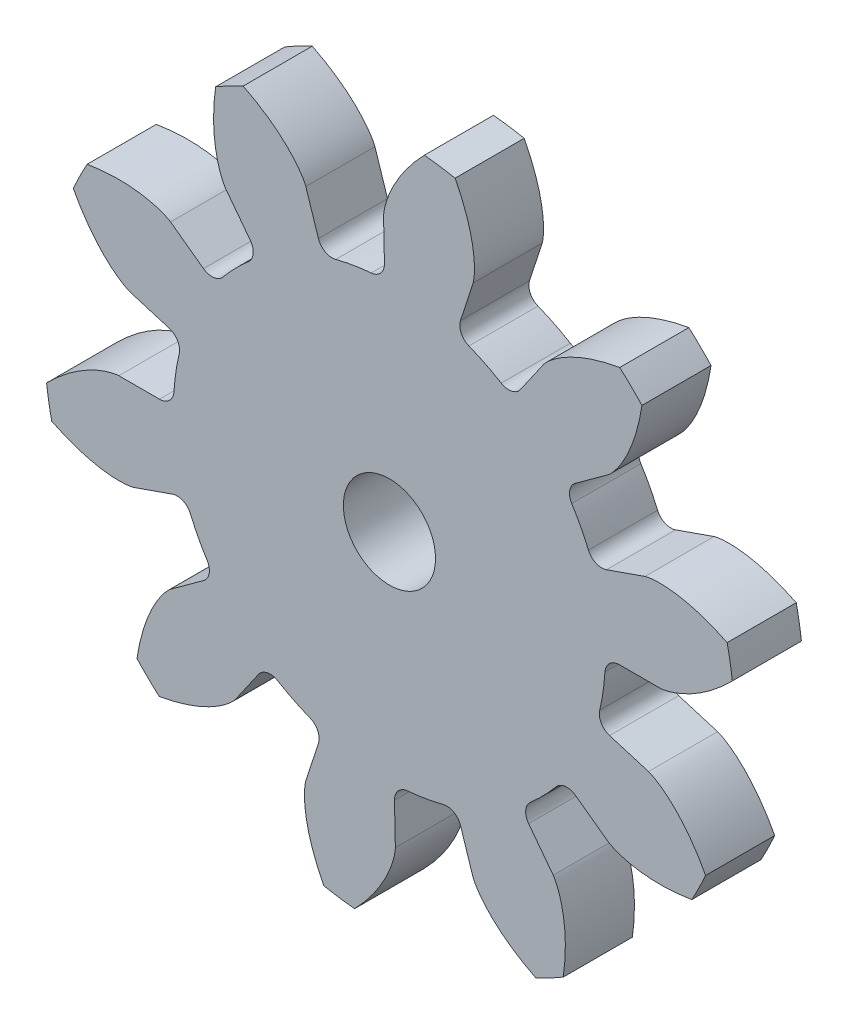
from build123d import *

# Parameters (mm, degrees)
BOSS_EXTRUDE3_DEPTH      = 3
FILLET1_R                = 0.625
CIRPATTERN8_COUNT        = 10
CIRPATTERN8_COPY_1_DEPTH = 3
CIRPATTERN8_COPY_2_DEPTH = 3
CIRPATTERN8_COPY_3_DEPTH = 3
CIRPATTERN8_COPY_4_DEPTH = 3
CIRPATTERN8_COPY_5_DEPTH = 3
CIRPATTERN8_COPY_6_DEPTH = 3
CIRPATTERN8_COPY_7_DEPTH = 3
CIRPATTERN8_COPY_8_DEPTH = 3
CIRPATTERN8_COPY_9_DEPTH = 3
FILLET1_OF_CIRPATTERN8_R = 0.625
SKETCH3_R                = 2
CUT_EXTRUDE2_DEPTH       = 4.0000001


with BuildPart() as part:
    # Sketch1 → Boss-Extrude3 (new body)
    with BuildSketch(Plane.XY):
        with BuildLine():
            Line((9.375, 0), (11.74615776, 0))
            add(Edge.make_bspline(
                [(11.74615776, 0), (11.754841732, 0.000183768), (11.779179169, 0.001267888), (11.825088632, 0.005562117), (11.899691958, 0.015746104), (11.994171849, 0.033372696), (12.115394291, 0.0614606), (12.256834487, 0.101322639), (12.410572757, 0.152161687), (12.575722813, 0.214972968), (12.738406771, 0.284201046), (12.898564829, 0.359289485), (13.056063732, 0.439482048), (13.244229139, 0.542891509), (13.466087479, 0.675556037), (13.719390719, 0.842943905), (13.999170912, 1.047118123), (14.275580492, 1.270025494), (14.531397244, 1.493742481), (14.716666587, 1.670363519), (14.8331519, 1.786067897), (14.886668048, 1.84041148)],
                knots=[0, 0, 0, 0, 0, 0.005376748, 0.015083688, 0.02853182, 0.046610139, 0.064854849, 0.092110525, 0.119476175, 0.146842495, 0.174208853, 0.201574955, 0.228941013, 0.256307345, 0.307035032, 0.361767351, 0.41649966, 0.471231936, 0.525964281, 0.573449371, 0.573449371, 0.573449371, 0.573449371, 0.573449371], degree=4))
            ThreePointArc((14.886668048, 1.84041148), (14.841516096, 2.174718367), (14.788857648, 2.507925333))
            Line((14.788857648, 2.507925333), (9.24303603, 1.567453333))
            ThreePointArc((9.24303603, 1.567453333), (9.341950754, 0.786499275), (9.375, 0))
        make_face()
        with BuildLine():
            ThreePointArc((-9.24303603, -1.567453333), (0.786499275, -9.341950754), (9.375, 0))
            ThreePointArc((9.375, 0), (9.341950754, 0.786499275), (9.24303603, 1.567453333))
            Line((9.24303603, 1.567453333), (-9.24303603, -1.567453333))
        make_face()
        with BuildLine():
            Line((-9.24303603, -1.567453333), (9.24303603, 1.567453333))
            ThreePointArc((9.24303603, 1.567453333), (-1.567453333, 9.24303603), (-9.24303603, -1.567453333))
        make_face()
    boss_extrude3 = extrude(amount=BOSS_EXTRUDE3_DEPTH)

    # Mirror2: Boss-Extrude3 across plane
    add(boss_extrude3.mirror(Plane(origin=(0, 0, 3), x_dir=(0, 0, 1), z_dir=(0.167195022, -0.985923843, 0))))

    # Fillet1
    fillet1_edges = [part.edges().sort_by_distance(p)[0] for p in [
        (9.375, 0, 1.5),
        (8.850859211, 3.090779228, 1.5),
    ]]
    fillet(fillet1_edges, radius=FILLET1_R)

    # CirPattern8: Boss-Extrude3 ×10 about axis
    cirpattern8_axis = Axis((0, 0, 3), (0, 0, -1))
    for i in range(1, CIRPATTERN8_COUNT):
        add(boss_extrude3.rotate(cirpattern8_axis, i * 360 / CIRPATTERN8_COUNT))

    # CirPattern8 copy 1 sketch → CirPattern8 copy 1 (add)
    with BuildSketch(Plane(origin=(0, 0, 0), x_dir=(0.957569063, -0.288203903, 0), z_dir=(0, 0, 1))):
        with BuildLine():
            Line((9.375, 0), (11.74615776, 0))
            add(Edge.make_bspline(
                [(11.74615776, 0), (11.754841732, -0.000183768), (11.779179169, -0.001267888), (11.825088632, -0.005562117), (11.899691958, -0.015746104), (11.994171849, -0.033372696), (12.115394291, -0.0614606), (12.256834487, -0.101322639), (12.410572757, -0.152161687), (12.575722813, -0.214972968), (12.738406771, -0.284201046), (12.898564829, -0.359289485), (13.056063732, -0.439482048), (13.244229139, -0.542891509), (13.466087479, -0.675556037), (13.719390719, -0.842943905), (13.999170912, -1.047118123), (14.275580492, -1.270025494), (14.531397244, -1.493742481), (14.716666587, -1.670363519), (14.8331519, -1.786067897), (14.886668048, -1.84041148)],
                knots=[0, 0, 0, 0, 0, 0.005376748, 0.015083688, 0.02853182, 0.046610139, 0.064854849, 0.092110525, 0.119476175, 0.146842495, 0.174208853, 0.201574955, 0.228941013, 0.256307345, 0.307035032, 0.361767351, 0.41649966, 0.471231936, 0.525964281, 0.573449371, 0.573449371, 0.573449371, 0.573449371, 0.573449371], degree=4))
            ThreePointArc((14.886668048, -1.84041148), (14.841516096, -2.174718367), (14.788857648, -2.507925333))
            Line((14.788857648, -2.507925333), (9.24303603, -1.567453333))
            ThreePointArc((9.24303603, -1.567453333), (9.341950754, -0.786499275), (9.375, 0))
        make_face()
        with BuildLine():
            ThreePointArc((-9.24303603, 1.567453333), (0.786499275, 9.341950754), (9.375, 0))
            ThreePointArc((9.375, 0), (9.341950754, -0.786499275), (9.24303603, -1.567453333))
            Line((9.24303603, -1.567453333), (-9.24303603, 1.567453333))
        make_face()
        with BuildLine():
            Line((-9.24303603, 1.567453333), (9.24303603, -1.567453333))
            ThreePointArc((9.24303603, -1.567453333), (-1.567453333, -9.24303603), (-9.24303603, 1.567453333))
        make_face()
    extrude(amount=CIRPATTERN8_COPY_1_DEPTH)

    # CirPattern8 copy 2 sketch → CirPattern8 copy 2 (add)
    with BuildSketch(Plane(origin=(0, 0, 0), x_dir=(0.605287641, -0.796006829, 0), z_dir=(0, 0, 1))):
        with BuildLine():
            Line((9.375, 0), (11.74615776, 0))
            add(Edge.make_bspline(
                [(11.74615776, 0), (11.754841732, -0.000183768), (11.779179169, -0.001267888), (11.825088632, -0.005562117), (11.899691958, -0.015746104), (11.994171849, -0.033372696), (12.115394291, -0.0614606), (12.256834487, -0.101322639), (12.410572757, -0.152161687), (12.575722813, -0.214972968), (12.738406771, -0.284201046), (12.898564829, -0.359289485), (13.056063732, -0.439482048), (13.244229139, -0.542891509), (13.466087479, -0.675556037), (13.719390719, -0.842943905), (13.999170912, -1.047118123), (14.275580492, -1.270025494), (14.531397244, -1.493742481), (14.716666587, -1.670363519), (14.8331519, -1.786067897), (14.886668048, -1.84041148)],
                knots=[0, 0, 0, 0, 0, 0.005376748, 0.015083688, 0.02853182, 0.046610139, 0.064854849, 0.092110525, 0.119476175, 0.146842495, 0.174208853, 0.201574955, 0.228941013, 0.256307345, 0.307035032, 0.361767351, 0.41649966, 0.471231936, 0.525964281, 0.573449371, 0.573449371, 0.573449371, 0.573449371, 0.573449371], degree=4))
            ThreePointArc((14.886668048, -1.84041148), (14.841516096, -2.174718367), (14.788857648, -2.507925333))
            Line((14.788857648, -2.507925333), (9.24303603, -1.567453333))
            ThreePointArc((9.24303603, -1.567453333), (9.341950754, -0.786499275), (9.375, 0))
        make_face()
        with BuildLine():
            ThreePointArc((-9.24303603, 1.567453333), (0.786499275, 9.341950754), (9.375, 0))
            ThreePointArc((9.375, 0), (9.341950754, -0.786499275), (9.24303603, -1.567453333))
            Line((9.24303603, -1.567453333), (-9.24303603, 1.567453333))
        make_face()
        with BuildLine():
            Line((-9.24303603, 1.567453333), (9.24303603, -1.567453333))
            ThreePointArc((9.24303603, -1.567453333), (-1.567453333, -9.24303603), (-9.24303603, 1.567453333))
        make_face()
    extrude(amount=CIRPATTERN8_COPY_2_DEPTH)

    # CirPattern8 copy 3 sketch → CirPattern8 copy 3 (add)
    with BuildSketch(Plane(origin=(0, 0, 0), x_dir=(0.021806914, -0.999762201, 0), z_dir=(0, 0, 1))):
        with BuildLine():
            Line((9.375, 0), (11.74615776, 0))
            add(Edge.make_bspline(
                [(11.74615776, 0), (11.754841732, -0.000183768), (11.779179169, -0.001267888), (11.825088632, -0.005562117), (11.899691958, -0.015746104), (11.994171849, -0.033372696), (12.115394291, -0.0614606), (12.256834487, -0.101322639), (12.410572757, -0.152161687), (12.575722813, -0.214972968), (12.738406771, -0.284201046), (12.898564829, -0.359289485), (13.056063732, -0.439482048), (13.244229139, -0.542891509), (13.466087479, -0.675556037), (13.719390719, -0.842943905), (13.999170912, -1.047118123), (14.275580492, -1.270025494), (14.531397244, -1.493742481), (14.716666587, -1.670363519), (14.8331519, -1.786067897), (14.886668048, -1.84041148)],
                knots=[0, 0, 0, 0, 0, 0.005376748, 0.015083688, 0.02853182, 0.046610139, 0.064854849, 0.092110525, 0.119476175, 0.146842495, 0.174208853, 0.201574955, 0.228941013, 0.256307345, 0.307035032, 0.361767351, 0.41649966, 0.471231936, 0.525964281, 0.573449371, 0.573449371, 0.573449371, 0.573449371, 0.573449371], degree=4))
            ThreePointArc((14.886668048, -1.84041148), (14.841516096, -2.174718367), (14.788857648, -2.507925333))
            Line((14.788857648, -2.507925333), (9.24303603, -1.567453333))
            ThreePointArc((9.24303603, -1.567453333), (9.341950754, -0.786499275), (9.375, 0))
        make_face()
        with BuildLine():
            ThreePointArc((-9.24303603, 1.567453333), (0.786499275, 9.341950754), (9.375, 0))
            ThreePointArc((9.375, 0), (9.341950754, -0.786499275), (9.24303603, -1.567453333))
            Line((9.24303603, -1.567453333), (-9.24303603, 1.567453333))
        make_face()
        with BuildLine():
            Line((-9.24303603, 1.567453333), (9.24303603, -1.567453333))
            ThreePointArc((9.24303603, -1.567453333), (-1.567453333, -9.24303603), (-9.24303603, 1.567453333))
        make_face()
    extrude(amount=CIRPATTERN8_COPY_3_DEPTH)

    # CirPattern8 copy 4 sketch → CirPattern8 copy 4 (add)
    with BuildSketch(Plane(origin=(0, 0, 0), x_dir=(-0.570003314, -0.821642393, 0), z_dir=(0, 0, 1))):
        with BuildLine():
            Line((9.375, 0), (11.74615776, 0))
            add(Edge.make_bspline(
                [(11.74615776, 0), (11.754841732, -0.000183768), (11.779179169, -0.001267888), (11.825088632, -0.005562117), (11.899691958, -0.015746104), (11.994171849, -0.033372696), (12.115394291, -0.0614606), (12.256834487, -0.101322639), (12.410572757, -0.152161687), (12.575722813, -0.214972968), (12.738406771, -0.284201046), (12.898564829, -0.359289485), (13.056063732, -0.439482048), (13.244229139, -0.542891509), (13.466087479, -0.675556037), (13.719390719, -0.842943905), (13.999170912, -1.047118123), (14.275580492, -1.270025494), (14.531397244, -1.493742481), (14.716666587, -1.670363519), (14.8331519, -1.786067897), (14.886668048, -1.84041148)],
                knots=[0, 0, 0, 0, 0, 0.005376748, 0.015083688, 0.02853182, 0.046610139, 0.064854849, 0.092110525, 0.119476175, 0.146842495, 0.174208853, 0.201574955, 0.228941013, 0.256307345, 0.307035032, 0.361767351, 0.41649966, 0.471231936, 0.525964281, 0.573449371, 0.573449371, 0.573449371, 0.573449371, 0.573449371], degree=4))
            ThreePointArc((14.886668048, -1.84041148), (14.841516096, -2.174718367), (14.788857648, -2.507925333))
            Line((14.788857648, -2.507925333), (9.24303603, -1.567453333))
            ThreePointArc((9.24303603, -1.567453333), (9.341950754, -0.786499275), (9.375, 0))
        make_face()
        with BuildLine():
            ThreePointArc((-9.24303603, 1.567453333), (0.786499275, 9.341950754), (9.375, 0))
            ThreePointArc((9.375, 0), (9.341950754, -0.786499275), (9.24303603, -1.567453333))
            Line((9.24303603, -1.567453333), (-9.24303603, 1.567453333))
        make_face()
        with BuildLine():
            Line((-9.24303603, 1.567453333), (9.24303603, -1.567453333))
            ThreePointArc((9.24303603, -1.567453333), (-1.567453333, -9.24303603), (-9.24303603, 1.567453333))
        make_face()
    extrude(amount=CIRPATTERN8_COPY_4_DEPTH)

    # CirPattern8 copy 5 sketch → CirPattern8 copy 5 (add)
    with BuildSketch(Plane(origin=(0, 0, 0), x_dir=(-0.944091649, -0.329683118, 0), z_dir=(0, 0, 1))):
        with BuildLine():
            Line((9.375, 0), (11.74615776, 0))
            add(Edge.make_bspline(
                [(11.74615776, 0), (11.754841732, -0.000183768), (11.779179169, -0.001267888), (11.825088632, -0.005562117), (11.899691958, -0.015746104), (11.994171849, -0.033372696), (12.115394291, -0.0614606), (12.256834487, -0.101322639), (12.410572757, -0.152161687), (12.575722813, -0.214972968), (12.738406771, -0.284201046), (12.898564829, -0.359289485), (13.056063732, -0.439482048), (13.244229139, -0.542891509), (13.466087479, -0.675556037), (13.719390719, -0.842943905), (13.999170912, -1.047118123), (14.275580492, -1.270025494), (14.531397244, -1.493742481), (14.716666587, -1.670363519), (14.8331519, -1.786067897), (14.886668048, -1.84041148)],
                knots=[0, 0, 0, 0, 0, 0.005376748, 0.015083688, 0.02853182, 0.046610139, 0.064854849, 0.092110525, 0.119476175, 0.146842495, 0.174208853, 0.201574955, 0.228941013, 0.256307345, 0.307035032, 0.361767351, 0.41649966, 0.471231936, 0.525964281, 0.573449371, 0.573449371, 0.573449371, 0.573449371, 0.573449371], degree=4))
            ThreePointArc((14.886668048, -1.84041148), (14.841516096, -2.174718367), (14.788857648, -2.507925333))
            Line((14.788857648, -2.507925333), (9.24303603, -1.567453333))
            ThreePointArc((9.24303603, -1.567453333), (9.341950754, -0.786499275), (9.375, 0))
        make_face()
        with BuildLine():
            ThreePointArc((-9.24303603, 1.567453333), (0.786499275, 9.341950754), (9.375, 0))
            ThreePointArc((9.375, 0), (9.341950754, -0.786499275), (9.24303603, -1.567453333))
            Line((9.24303603, -1.567453333), (-9.24303603, 1.567453333))
        make_face()
        with BuildLine():
            Line((-9.24303603, 1.567453333), (9.24303603, -1.567453333))
            ThreePointArc((9.24303603, -1.567453333), (-1.567453333, -9.24303603), (-9.24303603, 1.567453333))
        make_face()
    extrude(amount=CIRPATTERN8_COPY_5_DEPTH)

    # CirPattern8 copy 6 sketch → CirPattern8 copy 6 (add)
    with BuildSketch(Plane(origin=(0, 0, 0), x_dir=(-0.957569063, 0.288203903, 0), z_dir=(0, 0, 1))):
        with BuildLine():
            Line((9.375, 0), (11.74615776, 0))
            add(Edge.make_bspline(
                [(11.74615776, 0), (11.754841732, -0.000183768), (11.779179169, -0.001267888), (11.825088632, -0.005562117), (11.899691958, -0.015746104), (11.994171849, -0.033372696), (12.115394291, -0.0614606), (12.256834487, -0.101322639), (12.410572757, -0.152161687), (12.575722813, -0.214972968), (12.738406771, -0.284201046), (12.898564829, -0.359289485), (13.056063732, -0.439482048), (13.244229139, -0.542891509), (13.466087479, -0.675556037), (13.719390719, -0.842943905), (13.999170912, -1.047118123), (14.275580492, -1.270025494), (14.531397244, -1.493742481), (14.716666587, -1.670363519), (14.8331519, -1.786067897), (14.886668048, -1.84041148)],
                knots=[0, 0, 0, 0, 0, 0.005376748, 0.015083688, 0.02853182, 0.046610139, 0.064854849, 0.092110525, 0.119476175, 0.146842495, 0.174208853, 0.201574955, 0.228941013, 0.256307345, 0.307035032, 0.361767351, 0.41649966, 0.471231936, 0.525964281, 0.573449371, 0.573449371, 0.573449371, 0.573449371, 0.573449371], degree=4))
            ThreePointArc((14.886668048, -1.84041148), (14.841516096, -2.174718367), (14.788857648, -2.507925333))
            Line((14.788857648, -2.507925333), (9.24303603, -1.567453333))
            ThreePointArc((9.24303603, -1.567453333), (9.341950754, -0.786499275), (9.375, 0))
        make_face()
        with BuildLine():
            ThreePointArc((-9.24303603, 1.567453333), (0.786499275, 9.341950754), (9.375, 0))
            ThreePointArc((9.375, 0), (9.341950754, -0.786499275), (9.24303603, -1.567453333))
            Line((9.24303603, -1.567453333), (-9.24303603, 1.567453333))
        make_face()
        with BuildLine():
            Line((-9.24303603, 1.567453333), (9.24303603, -1.567453333))
            ThreePointArc((9.24303603, -1.567453333), (-1.567453333, -9.24303603), (-9.24303603, 1.567453333))
        make_face()
    extrude(amount=CIRPATTERN8_COPY_6_DEPTH)

    # CirPattern8 copy 7 sketch → CirPattern8 copy 7 (add)
    with BuildSketch(Plane(origin=(0, 0, 0), x_dir=(-0.605287641, 0.796006829, 0), z_dir=(0, 0, 1))):
        with BuildLine():
            Line((9.375, 0), (11.74615776, 0))
            add(Edge.make_bspline(
                [(11.74615776, 0), (11.754841732, -0.000183768), (11.779179169, -0.001267888), (11.825088632, -0.005562117), (11.899691958, -0.015746104), (11.994171849, -0.033372696), (12.115394291, -0.0614606), (12.256834487, -0.101322639), (12.410572757, -0.152161687), (12.575722813, -0.214972968), (12.738406771, -0.284201046), (12.898564829, -0.359289485), (13.056063732, -0.439482048), (13.244229139, -0.542891509), (13.466087479, -0.675556037), (13.719390719, -0.842943905), (13.999170912, -1.047118123), (14.275580492, -1.270025494), (14.531397244, -1.493742481), (14.716666587, -1.670363519), (14.8331519, -1.786067897), (14.886668048, -1.84041148)],
                knots=[0, 0, 0, 0, 0, 0.005376748, 0.015083688, 0.02853182, 0.046610139, 0.064854849, 0.092110525, 0.119476175, 0.146842495, 0.174208853, 0.201574955, 0.228941013, 0.256307345, 0.307035032, 0.361767351, 0.41649966, 0.471231936, 0.525964281, 0.573449371, 0.573449371, 0.573449371, 0.573449371, 0.573449371], degree=4))
            ThreePointArc((14.886668048, -1.84041148), (14.841516096, -2.174718367), (14.788857648, -2.507925333))
            Line((14.788857648, -2.507925333), (9.24303603, -1.567453333))
            ThreePointArc((9.24303603, -1.567453333), (9.341950754, -0.786499275), (9.375, 0))
        make_face()
        with BuildLine():
            ThreePointArc((-9.24303603, 1.567453333), (0.786499275, 9.341950754), (9.375, 0))
            ThreePointArc((9.375, 0), (9.341950754, -0.786499275), (9.24303603, -1.567453333))
            Line((9.24303603, -1.567453333), (-9.24303603, 1.567453333))
        make_face()
        with BuildLine():
            Line((-9.24303603, 1.567453333), (9.24303603, -1.567453333))
            ThreePointArc((9.24303603, -1.567453333), (-1.567453333, -9.24303603), (-9.24303603, 1.567453333))
        make_face()
    extrude(amount=CIRPATTERN8_COPY_7_DEPTH)

    # CirPattern8 copy 8 sketch → CirPattern8 copy 8 (add)
    with BuildSketch(Plane(origin=(0, 0, 0), x_dir=(-0.021806914, 0.999762201, 0), z_dir=(0, 0, 1))):
        with BuildLine():
            Line((9.375, 0), (11.74615776, 0))
            add(Edge.make_bspline(
                [(11.74615776, 0), (11.754841732, -0.000183768), (11.779179169, -0.001267888), (11.825088632, -0.005562117), (11.899691958, -0.015746104), (11.994171849, -0.033372696), (12.115394291, -0.0614606), (12.256834487, -0.101322639), (12.410572757, -0.152161687), (12.575722813, -0.214972968), (12.738406771, -0.284201046), (12.898564829, -0.359289485), (13.056063732, -0.439482048), (13.244229139, -0.542891509), (13.466087479, -0.675556037), (13.719390719, -0.842943905), (13.999170912, -1.047118123), (14.275580492, -1.270025494), (14.531397244, -1.493742481), (14.716666587, -1.670363519), (14.8331519, -1.786067897), (14.886668048, -1.84041148)],
                knots=[0, 0, 0, 0, 0, 0.005376748, 0.015083688, 0.02853182, 0.046610139, 0.064854849, 0.092110525, 0.119476175, 0.146842495, 0.174208853, 0.201574955, 0.228941013, 0.256307345, 0.307035032, 0.361767351, 0.41649966, 0.471231936, 0.525964281, 0.573449371, 0.573449371, 0.573449371, 0.573449371, 0.573449371], degree=4))
            ThreePointArc((14.886668048, -1.84041148), (14.841516096, -2.174718367), (14.788857648, -2.507925333))
            Line((14.788857648, -2.507925333), (9.24303603, -1.567453333))
            ThreePointArc((9.24303603, -1.567453333), (9.341950754, -0.786499275), (9.375, 0))
        make_face()
        with BuildLine():
            ThreePointArc((-9.24303603, 1.567453333), (0.786499275, 9.341950754), (9.375, 0))
            ThreePointArc((9.375, 0), (9.341950754, -0.786499275), (9.24303603, -1.567453333))
            Line((9.24303603, -1.567453333), (-9.24303603, 1.567453333))
        make_face()
        with BuildLine():
            Line((-9.24303603, 1.567453333), (9.24303603, -1.567453333))
            ThreePointArc((9.24303603, -1.567453333), (-1.567453333, -9.24303603), (-9.24303603, 1.567453333))
        make_face()
    extrude(amount=CIRPATTERN8_COPY_8_DEPTH)

    # CirPattern8 copy 9 sketch → CirPattern8 copy 9 (add)
    with BuildSketch(Plane(origin=(0, 0, 0), x_dir=(0.570003314, 0.821642393, 0), z_dir=(0, 0, 1))):
        with BuildLine():
            Line((9.375, 0), (11.74615776, 0))
            add(Edge.make_bspline(
                [(11.74615776, 0), (11.754841732, -0.000183768), (11.779179169, -0.001267888), (11.825088632, -0.005562117), (11.899691958, -0.015746104), (11.994171849, -0.033372696), (12.115394291, -0.0614606), (12.256834487, -0.101322639), (12.410572757, -0.152161687), (12.575722813, -0.214972968), (12.738406771, -0.284201046), (12.898564829, -0.359289485), (13.056063732, -0.439482048), (13.244229139, -0.542891509), (13.466087479, -0.675556037), (13.719390719, -0.842943905), (13.999170912, -1.047118123), (14.275580492, -1.270025494), (14.531397244, -1.493742481), (14.716666587, -1.670363519), (14.8331519, -1.786067897), (14.886668048, -1.84041148)],
                knots=[0, 0, 0, 0, 0, 0.005376748, 0.015083688, 0.02853182, 0.046610139, 0.064854849, 0.092110525, 0.119476175, 0.146842495, 0.174208853, 0.201574955, 0.228941013, 0.256307345, 0.307035032, 0.361767351, 0.41649966, 0.471231936, 0.525964281, 0.573449371, 0.573449371, 0.573449371, 0.573449371, 0.573449371], degree=4))
            ThreePointArc((14.886668048, -1.84041148), (14.841516096, -2.174718367), (14.788857648, -2.507925333))
            Line((14.788857648, -2.507925333), (9.24303603, -1.567453333))
            ThreePointArc((9.24303603, -1.567453333), (9.341950754, -0.786499275), (9.375, 0))
        make_face()
        with BuildLine():
            ThreePointArc((-9.24303603, 1.567453333), (0.786499275, 9.341950754), (9.375, 0))
            ThreePointArc((9.375, 0), (9.341950754, -0.786499275), (9.24303603, -1.567453333))
            Line((9.24303603, -1.567453333), (-9.24303603, 1.567453333))
        make_face()
        with BuildLine():
            Line((-9.24303603, 1.567453333), (9.24303603, -1.567453333))
            ThreePointArc((9.24303603, -1.567453333), (-1.567453333, -9.24303603), (-9.24303603, 1.567453333))
        make_face()
    extrude(amount=CIRPATTERN8_COPY_9_DEPTH)

    # Fillet1 of CirPattern8
    fillet1_of_cirpattern8_edges = [part.edges().sort_by_distance(p)[0] for p in [
        (7.584534322, -5.51048674, 1.5),
        (8.977209964, -2.701911593, 1.5),
        (2.897034322, -8.91615484, 1.5),
        (5.674571636, -7.46256402, 1.5),
        (-2.897034322, -8.91615484, 1.5),
        (0.204439814, -9.372770634, 1.5),
        (-7.584534322, -5.51048674, 1.5),
        (-5.343781068, -7.702897435, 1.5),
        (-9.375, 0, 1.5),
        (-8.850859211, -3.090779228, 1.5),
        (-7.584534322, 5.51048674, 1.5),
        (-8.977209964, 2.701911593, 1.5),
        (-2.897034322, 8.91615484, 1.5),
        (-5.674571636, 7.46256402, 1.5),
        (2.897034322, 8.91615484, 1.5),
        (-0.204439814, 9.372770634, 1.5),
        (7.584534322, 5.51048674, 1.5),
        (5.343781068, 7.702897435, 1.5),
    ]]
    fillet(fillet1_of_cirpattern8_edges, radius=FILLET1_OF_CIRPATTERN8_R)

    # Sketch3 → Cut-Extrude2 (cut, through all)
    with BuildSketch(Plane.XY.offset(3)):
        Circle(SKETCH3_R)
    extrude(amount=-CUT_EXTRUDE2_DEPTH, mode=Mode.SUBTRACT)


solid = part.part
